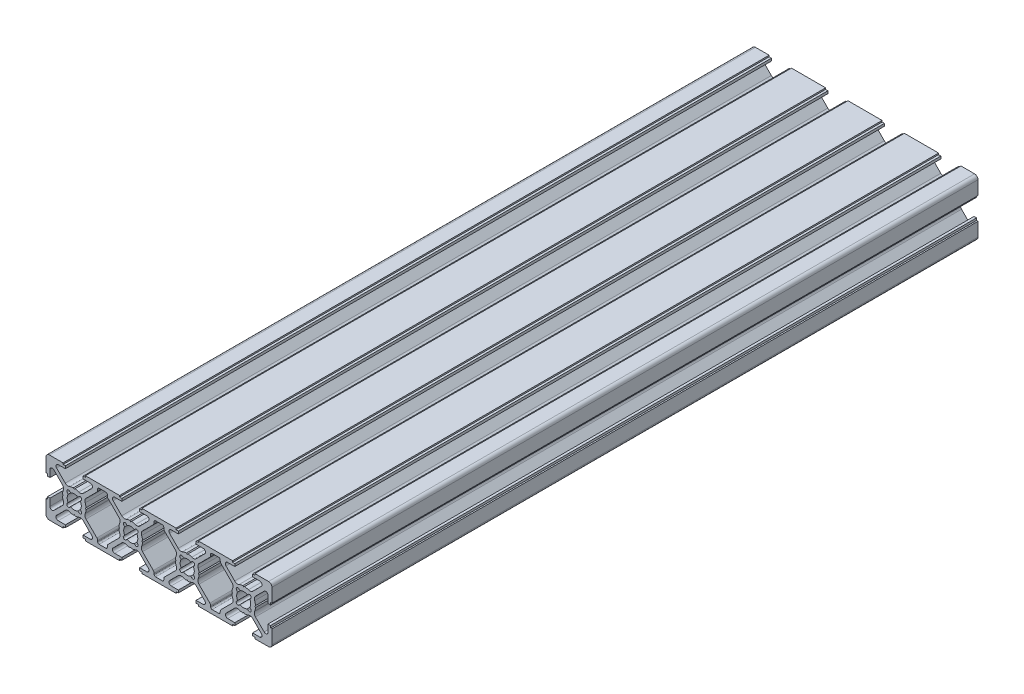
from build123d import *

# Parameters (mm, degrees)
Y_KSEKLIK_EKSTR_ZYON1_DEPTH = 250


with BuildPart() as part:
    # Model → Yükseklik-Ekstrüzyon1 (new body)
    with BuildSketch(Plane.XY):
        with BuildLine():
            Line((-8.800004195, -10.000004195), (-3.950004195, -10.000004195))
            Line((-3.950004195, -10.000004195), (-3.950004195, -9.499995805))
            Line((-3.950004195, -9.499995805), (-3.147504195, -9.499995805))
            Line((-3.147504195, -9.499995805), (-3.147504195, -8.599995805))
            Line((-3.147504195, -8.599995805), (-5.678683852, -8.599995805))
            ThreePointArc((-5.678683852, -8.599995805), (-6.417787478, -8.106142551), (-6.244369277, -7.23431038))
            Line((-6.244369277, -7.23431038), (-3.178748666, -4.168689769))
            ThreePointArc((-3.178748666, -4.168689769), (-2.455097993, -3.783144936), (-1.639430046, -3.866816407))
            ThreePointArc((-1.639430046, -3.866816407), (-0.978142037, -4.084511985), (-0.289977679, -4.189977678))
            Line((-0.289977679, -4.189977678), (0, -3.9))
            Line((0, -3.9), (0.289977678, -4.189977678))
            ThreePointArc((0.289977678, -4.189977678), (0.978142036, -4.084511985), (1.639430046, -3.866816407))
            ThreePointArc((1.639430046, -3.866816407), (2.453899272, -3.782053175), (3.17678595, -4.166734572))
            Line((3.17678595, -4.166734572), (6.244365517, -7.234314139))
            ThreePointArc((6.244365517, -7.234314139), (6.417783718, -8.10614631), (5.678680092, -8.599999564))
            Line((5.678680092, -8.599999564), (3.147500435, -8.599999564))
            Line((3.147500435, -8.599999564), (3.147500435, -9.499999564))
            Line((3.147500435, -9.499999564), (3.950000435, -9.499999564))
            Line((3.950000435, -9.499999564), (3.950000435, -10.000004195))
            Line((3.950000435, -10.000004195), (16.049995805, -10.000004195))
            Line((16.049995805, -10.000004195), (16.049995805, -9.500000435))
            Line((16.049995805, -9.500000435), (16.852495805, -9.500000435))
            Line((16.852495805, -9.500000435), (16.852495805, -8.599995805))
            Line((16.852495805, -8.599995805), (14.321316148, -8.599995805))
            ThreePointArc((14.321316148, -8.599995805), (13.582212522, -8.106142551), (13.755630723, -7.23431038))
            Line((13.755630723, -7.23431038), (16.821251334, -4.168689769))
            ThreePointArc((16.821251334, -4.168689769), (17.544902007, -3.783144936), (18.360569954, -3.866816407))
            ThreePointArc((18.360569954, -3.866816407), (19.021857963, -4.084511985), (19.710022321, -4.189977678))
            Line((19.710022321, -4.189977678), (20, -3.9))
            Line((20, -3.9), (20.289977678, -4.189977678))
            ThreePointArc((20.289977678, -4.189977678), (20.978142036, -4.084511985), (21.639430046, -3.866816407))
            ThreePointArc((21.639430046, -3.866816407), (22.453899272, -3.782053175), (23.17678595, -4.166734572))
            Line((23.17678595, -4.166734572), (26.244365517, -7.234314139))
            ThreePointArc((26.244365517, -7.234314139), (26.417783718, -8.10614631), (25.678680092, -8.599999564))
            Line((25.678680092, -8.599999564), (23.147500435, -8.599999564))
            Line((23.147500435, -8.599999564), (23.147500435, -9.499999564))
            Line((23.147500435, -9.499999564), (23.950000435, -9.499999564))
            Line((23.950000435, -9.499999564), (23.950000435, -10.000004195))
            Line((23.950000435, -10.000004195), (36.049995805, -10.000004195))
            Line((36.049995805, -10.000004195), (36.049995805, -9.500000435))
            Line((36.049995805, -9.500000435), (36.852495805, -9.500000435))
            Line((36.852495805, -9.500000435), (36.852495805, -8.599995805))
            Line((36.852495805, -8.599995805), (34.321316148, -8.599995805))
            ThreePointArc((34.321316148, -8.599995805), (33.582212522, -8.106142551), (33.755630724, -7.23431038))
            Line((33.755630724, -7.23431038), (36.821251334, -4.168689769))
            ThreePointArc((36.821251334, -4.168689769), (37.544902007, -3.783144936), (38.360569954, -3.866816407))
            ThreePointArc((38.360569954, -3.866816407), (39.021857964, -4.084511985), (39.710022322, -4.189977678))
            Line((39.710022322, -4.189977678), (40, -3.9))
            Line((40, -3.9), (40.289977679, -4.189977678))
            ThreePointArc((40.289977679, -4.189977678), (40.978142037, -4.084511985), (41.639430046, -3.866816407))
            ThreePointArc((41.639430046, -3.866816407), (42.453899273, -3.782053175), (43.17678595, -4.166734572))
            Line((43.17678595, -4.166734572), (46.244365517, -7.234314139))
            ThreePointArc((46.244365517, -7.234314139), (46.417783718, -8.10614631), (45.678680092, -8.599999564))
            Line((45.678680092, -8.599999564), (43.147500436, -8.599999564))
            Line((43.147500436, -8.599999564), (43.147500436, -9.499999564))
            Line((43.147500436, -9.499999564), (43.950000436, -9.499999564))
            Line((43.950000436, -9.499999564), (43.950000436, -10.000004195))
            Line((43.950000436, -10.000004195), (56.049995805, -10.000004195))
            Line((56.049995805, -10.000004195), (56.049995805, -9.500000435))
            Line((56.049995805, -9.500000435), (56.852495805, -9.500000435))
            Line((56.852495805, -9.500000435), (56.852495805, -8.599995805))
            Line((56.852495805, -8.599995805), (54.321316148, -8.599995805))
            ThreePointArc((54.321316148, -8.599995805), (53.582212522, -8.106142551), (53.755630723, -7.23431038))
            Line((53.755630723, -7.23431038), (56.821251334, -4.168689769))
            ThreePointArc((56.821251334, -4.168689769), (57.544902007, -3.783144936), (58.360569954, -3.866816407))
            ThreePointArc((58.360569954, -3.866816407), (59.021857963, -4.084511985), (59.710022322, -4.189977678))
            Line((59.710022322, -4.189977678), (60, -3.9))
            Line((60, -3.9), (60.289977678, -4.189977678))
            ThreePointArc((60.289977678, -4.189977678), (60.978142037, -4.084511985), (61.639430046, -3.866816407))
            ThreePointArc((61.639430046, -3.866816407), (62.453899273, -3.782053175), (63.17678595, -4.166734572))
            Line((63.17678595, -4.166734572), (66.244365517, -7.234314139))
            ThreePointArc((66.244365517, -7.234314139), (66.417783718, -8.10614631), (65.678680092, -8.599999564))
            Line((65.678680092, -8.599999564), (63.147500436, -8.599999564))
            Line((63.147500436, -8.599999564), (63.147500436, -9.499999564))
            Line((63.147500436, -9.499999564), (63.950000436, -9.499999564))
            Line((63.950000436, -9.499999564), (63.950000436, -10.000004195))
            Line((63.950000436, -10.000004195), (68.800000436, -10.000004195))
            ThreePointArc((68.800000436, -10.000004195), (69.648528573, -9.648532332), (70.000000435, -8.800004195))
            Line((70.000000435, -8.800004195), (70.000000435, -3.950004195))
            Line((70.000000435, -3.950004195), (69.499995805, -3.950004195))
            Line((69.499995805, -3.950004195), (69.499995805, -3.147739195))
            Line((69.499995805, -3.147739195), (68.599995805, -3.147739195))
            Line((68.599995805, -3.147739195), (68.599995805, -5.678683851))
            ThreePointArc((68.599995805, -5.678683851), (68.106142551, -6.417787477), (67.23431038, -6.244369276))
            Line((67.23431038, -6.244369276), (64.168689769, -3.178748666))
            ThreePointArc((64.168689769, -3.178748666), (63.783144936, -2.455097993), (63.866816407, -1.639430046))
            ThreePointArc((63.866816407, -1.639430046), (64.084511985, -0.978142036), (64.189977678, -0.289977678))
            Line((64.189977678, -0.289977678), (63.9, 0))
            Line((63.9, 0), (64.189977678, 0.289977678))
            ThreePointArc((64.189977678, 0.289977678), (64.084511985, 0.978142037), (63.866816407, 1.639430046))
            ThreePointArc((63.866816407, 1.639430046), (63.782053175, 2.453899272), (64.166734573, 3.17678595))
            Line((64.166734573, 3.17678595), (67.23431414, 6.244365517))
            ThreePointArc((67.23431414, 6.244365517), (68.106146311, 6.417783718), (68.599999565, 5.678680092))
            Line((68.599999565, 5.678680092), (68.599999565, 3.147500436))
            Line((68.599999565, 3.147500436), (69.500000436, 3.147500436))
            Line((69.500000436, 3.147500436), (69.500000436, 3.949999564))
            Line((69.500000436, 3.949999564), (70.000000435, 3.949999564))
            Line((70.000000435, 3.949999564), (70.000000435, 8.799992045))
            ThreePointArc((70.000000435, 8.799992045), (69.648529902, 9.648522613), (68.800000435, 9.999995805))
            Line((68.800000435, 9.999995805), (63.950000435, 9.999995805))
            Line((63.950000435, 9.999995805), (63.950000435, 9.499999564))
            Line((63.950000435, 9.499999564), (63.147500435, 9.499999564))
            Line((63.147500435, 9.499999564), (63.147500435, 8.599999564))
            Line((63.147500435, 8.599999564), (65.678680092, 8.599999564))
            ThreePointArc((65.678680092, 8.599999564), (66.417783718, 8.10614631), (66.244365517, 7.23431414))
            Line((66.244365517, 7.23431414), (63.17678595, 4.166734573))
            ThreePointArc((63.17678595, 4.166734573), (62.453899272, 3.782053175), (61.639430046, 3.866816407))
            ThreePointArc((61.639430046, 3.866816407), (60.978142037, 4.084511985), (60.289977678, 4.189977678))
            Line((60.289977678, 4.189977678), (60, 3.9))
            Line((60, 3.9), (59.710022322, 4.189977679))
            ThreePointArc((59.710022322, 4.189977679), (59.021857964, 4.084511985), (58.360569954, 3.866816407))
            ThreePointArc((58.360569954, 3.866816407), (57.544902007, 3.783144936), (56.821251334, 4.168689769))
            Line((56.821251334, 4.168689769), (53.755630724, 7.23431038))
            ThreePointArc((53.755630724, 7.23431038), (53.582212522, 8.106142551), (54.321316148, 8.599995805))
            Line((54.321316148, 8.599995805), (56.852500435, 8.599995805))
            Line((56.852500435, 8.599995805), (56.852500435, 9.499995805))
            Line((56.852500435, 9.499995805), (56.050000435, 9.499995805))
            Line((56.050000435, 9.499995805), (56.050000435, 9.999995805))
            Line((56.050000435, 9.999995805), (43.950000436, 9.999995805))
            Line((43.950000436, 9.999995805), (43.950000436, 9.499999564))
            Line((43.950000436, 9.499999564), (43.147500436, 9.499999564))
            Line((43.147500436, 9.499999564), (43.147500436, 8.599999564))
            Line((43.147500436, 8.599999564), (45.678680092, 8.599999564))
            ThreePointArc((45.678680092, 8.599999564), (46.417783718, 8.10614631), (46.244365517, 7.234314139))
            Line((46.244365517, 7.234314139), (43.17678595, 4.166734573))
            ThreePointArc((43.17678595, 4.166734573), (42.453899273, 3.782053175), (41.639430046, 3.866816407))
            ThreePointArc((41.639430046, 3.866816407), (40.978142037, 4.084511985), (40.289977679, 4.189977678))
            Line((40.289977679, 4.189977678), (40, 3.9))
            Line((40, 3.9), (39.710022322, 4.189977678))
            ThreePointArc((39.710022322, 4.189977678), (39.021857964, 4.084511985), (38.360569954, 3.866816407))
            ThreePointArc((38.360569954, 3.866816407), (37.544902007, 3.783144936), (36.821251334, 4.168689769))
            Line((36.821251334, 4.168689769), (33.755630724, 7.23431038))
            ThreePointArc((33.755630724, 7.23431038), (33.582212522, 8.106142551), (34.321316149, 8.599995805))
            Line((34.321316149, 8.599995805), (36.852500436, 8.599995805))
            Line((36.852500436, 8.599995805), (36.852500436, 9.499995805))
            Line((36.852500436, 9.499995805), (36.050000436, 9.499995805))
            Line((36.050000436, 9.499995805), (36.050000436, 9.999995805))
            Line((36.050000436, 9.999995805), (23.950000435, 9.999995805))
            Line((23.950000435, 9.999995805), (23.950000435, 9.499999564))
            Line((23.950000435, 9.499999564), (23.147500435, 9.499999564))
            Line((23.147500435, 9.499999564), (23.147500435, 8.599999564))
            Line((23.147500435, 8.599999564), (25.678680092, 8.599999564))
            ThreePointArc((25.678680092, 8.599999564), (26.417783718, 8.10614631), (26.244365517, 7.234314139))
            Line((26.244365517, 7.234314139), (23.17678595, 4.166734573))
            ThreePointArc((23.17678595, 4.166734573), (22.453899272, 3.782053175), (21.639430046, 3.866816407))
            ThreePointArc((21.639430046, 3.866816407), (20.978142036, 4.084511985), (20.289977678, 4.189977678))
            Line((20.289977678, 4.189977678), (20, 3.9))
            Line((20, 3.9), (19.710022321, 4.189977678))
            ThreePointArc((19.710022321, 4.189977678), (19.021857963, 4.084511985), (18.360569954, 3.866816407))
            ThreePointArc((18.360569954, 3.866816407), (17.544902007, 3.783144936), (16.821251334, 4.168689769))
            Line((16.821251334, 4.168689769), (13.755630723, 7.23431038))
            ThreePointArc((13.755630723, 7.23431038), (13.582212522, 8.106142551), (14.321316148, 8.599995805))
            Line((14.321316148, 8.599995805), (16.852500435, 8.599995805))
            Line((16.852500435, 8.599995805), (16.852500435, 9.499995805))
            Line((16.852500435, 9.499995805), (16.050000435, 9.499995805))
            Line((16.050000435, 9.499995805), (16.050000435, 9.999995805))
            Line((16.050000435, 9.999995805), (3.950000435, 9.999995805))
            Line((3.950000435, 9.999995805), (3.950000435, 9.499999565))
            Line((3.950000435, 9.499999565), (3.147500435, 9.499999565))
            Line((3.147500435, 9.499999565), (3.147500435, 8.599999565))
            Line((3.147500435, 8.599999565), (5.678680092, 8.599999565))
            ThreePointArc((5.678680092, 8.599999565), (6.417783718, 8.10614631), (6.244365517, 7.23431414))
            Line((6.244365517, 7.23431414), (3.17678595, 4.166734573))
            ThreePointArc((3.17678595, 4.166734573), (2.453899272, 3.782053175), (1.639430046, 3.866816407))
            ThreePointArc((1.639430046, 3.866816407), (0.978142036, 4.084511985), (0.289977678, 4.189977679))
            Line((0.289977678, 4.189977679), (0, 3.9))
            Line((0, 3.9), (-0.289977679, 4.189977678))
            ThreePointArc((-0.289977679, 4.189977678), (-0.978142037, 4.084511985), (-1.639430046, 3.866816407))
            ThreePointArc((-1.639430046, 3.866816407), (-2.455097993, 3.783144936), (-3.178748666, 4.168689769))
            Line((-3.178748666, 4.168689769), (-6.244369277, 7.23431038))
            ThreePointArc((-6.244369277, 7.23431038), (-6.417787478, 8.106142551), (-5.678683852, 8.599995805))
            Line((-5.678683852, 8.599995805), (-3.147504195, 8.599995805))
            Line((-3.147504195, 8.599995805), (-3.147504195, 9.499995805))
            Line((-3.147504195, 9.499995805), (-3.950004195, 9.499995805))
            Line((-3.950004195, 9.499995805), (-3.950004195, 9.999995805))
            Line((-3.950004195, 9.999995805), (-8.800004195, 9.999995805))
            ThreePointArc((-8.800004195, 9.999995805), (-9.648532333, 9.648523942), (-10.000004195, 8.799995805))
            Line((-10.000004195, 8.799995805), (-10.000004195, 3.949995805))
            Line((-10.000004195, 3.949995805), (-9.500004195, 3.949995805))
            Line((-9.500004195, 3.949995805), (-9.500004195, 3.147495805))
            Line((-9.500004195, 3.147495805), (-8.599999564, 3.147495805))
            Line((-8.599999564, 3.147495805), (-8.599999564, 5.678680092))
            ThreePointArc((-8.599999564, 5.678680092), (-8.10614631, 6.417783718), (-7.234314139, 6.244365517))
            Line((-7.234314139, 6.244365517), (-4.166734573, 3.17678595))
            ThreePointArc((-4.166734573, 3.17678595), (-3.782053175, 2.453899272), (-3.866816407, 1.639430046))
            ThreePointArc((-3.866816407, 1.639430046), (-4.084511985, 0.978142037), (-4.189977678, 0.289977678))
            Line((-4.189977678, 0.289977678), (-3.9, 0))
            Line((-3.9, 0), (-4.189977678, -0.289977678))
            ThreePointArc((-4.189977678, -0.289977678), (-4.084511985, -0.978142036), (-3.866816407, -1.639430046))
            ThreePointArc((-3.866816407, -1.639430046), (-3.783144936, -2.455097993), (-4.168689769, -3.178748666))
            Line((-4.168689769, -3.178748666), (-7.23431038, -6.244369276))
            ThreePointArc((-7.23431038, -6.244369276), (-8.106142551, -6.417787477), (-8.599995805, -5.678683851))
            Line((-8.599995805, -5.678683851), (-8.599995805, -3.147504195))
            Line((-8.599995805, -3.147504195), (-9.499995805, -3.147504195))
            Line((-9.499995805, -3.147504195), (-9.499995805, -3.950004195))
            Line((-9.499995805, -3.950004195), (-10.000004195, -3.950004195))
            Line((-10.000004195, -3.950004195), (-10.000004195, -8.800004195))
            ThreePointArc((-10.000004195, -8.800004195), (-9.648532333, -9.648532332), (-8.800004195, -10.000004195))
        make_face()
        with BuildLine():
            Line((62.140364299, 1.291836162), (62.474873734, 1.626345597))
            ThreePointArc((62.474873734, 1.626345597), (62.474873734, 2.474873734), (61.626345597, 2.474873734))
            Line((61.626345597, 2.474873734), (61.291836161, 2.140364299))
            ThreePointArc((61.291836161, 2.140364299), (60, 2.5), (58.708163839, 2.140364299))
            Line((58.708163839, 2.140364299), (58.373654403, 2.474873734))
            ThreePointArc((58.373654403, 2.474873734), (57.525126266, 2.474873734), (57.525126266, 1.626345597))
            Line((57.525126266, 1.626345597), (57.859635701, 1.291836162))
            ThreePointArc((57.859635701, 1.291836162), (57.5, 0), (57.859635701, -1.291836161))
            Line((57.859635701, -1.291836161), (57.525126266, -1.626345597))
            ThreePointArc((57.525126266, -1.626345597), (57.525126266, -2.474873734), (58.373654403, -2.474873734))
            Line((58.373654403, -2.474873734), (58.708163839, -2.140364299))
            ThreePointArc((58.708163839, -2.140364299), (60, -2.5), (61.291836162, -2.140364299))
            Line((61.291836162, -2.140364299), (61.626345597, -2.474873734))
            ThreePointArc((61.626345597, -2.474873734), (62.474873734, -2.474873734), (62.474873734, -1.626345597))
            Line((62.474873734, -1.626345597), (62.140364299, -1.291836161))
            ThreePointArc((62.140364299, -1.291836161), (62.5, 0), (62.140364299, 1.291836162))
        make_face(mode=Mode.SUBTRACT)
        with BuildLine():
            Line((55.834194285, -3.175856222), (51.989949494, -7.020101012))
            ThreePointArc((51.989949494, -7.020101012), (51.773176743, -7.344524361), (51.697056275, -7.727207794))
            Line((51.697056275, -7.727207794), (51.697056275, -8.1))
            ThreePointArc((51.697056275, -8.1), (51.550609666, -8.453553391), (51.197056275, -8.6))
            Line((51.197056275, -8.6), (48.802943725, -8.6))
            ThreePointArc((48.802943725, -8.6), (48.449390335, -8.453553391), (48.302943725, -8.1))
            Line((48.302943725, -8.1), (48.302943725, -7.727207794))
            ThreePointArc((48.302943725, -7.727207794), (48.226823258, -7.344524362), (48.010050506, -7.020101013))
            Line((48.010050506, -7.020101013), (44.165805715, -3.175856222))
            ThreePointArc((44.165805715, -3.175856222), (43.781533861, -2.453330896), (43.866816407, -1.639430046))
            ThreePointArc((43.866816407, -1.639430046), (44.084511985, -0.978142037), (44.189977678, -0.289977678))
            Line((44.189977678, -0.289977678), (43.9, 0))
            Line((43.9, 0), (44.189977678, 0.289977678))
            ThreePointArc((44.189977678, 0.289977678), (44.084511985, 0.978142037), (43.866816407, 1.639430046))
            ThreePointArc((43.866816407, 1.639430046), (43.781533861, 2.453330896), (44.165805715, 3.175856222))
            Line((44.165805715, 3.175856222), (48.010050506, 7.020101013))
            ThreePointArc((48.010050506, 7.020101013), (48.226823258, 7.344524362), (48.302943725, 7.727207794))
            Line((48.302943725, 7.727207794), (48.302943725, 8.1))
            ThreePointArc((48.302943725, 8.1), (48.449390335, 8.453553391), (48.802943725, 8.6))
            Line((48.802943725, 8.6), (51.197056275, 8.6))
            ThreePointArc((51.197056275, 8.6), (51.550609665, 8.453553391), (51.697056275, 8.1))
            Line((51.697056275, 8.1), (51.697056275, 7.727207794))
            ThreePointArc((51.697056275, 7.727207794), (51.773176742, 7.344524361), (51.989949494, 7.020101013))
            Line((51.989949494, 7.020101013), (55.834194285, 3.175856222))
            ThreePointArc((55.834194285, 3.175856222), (56.218466139, 2.453330896), (56.133183593, 1.639430046))
            ThreePointArc((56.133183593, 1.639430046), (55.915488015, 0.978142037), (55.810022322, 0.289977678))
            Line((55.810022322, 0.289977678), (56.1, 0))
            Line((56.1, 0), (55.810022322, -0.289977678))
            ThreePointArc((55.810022322, -0.289977678), (55.915488015, -0.978142037), (56.133183593, -1.639430046))
            ThreePointArc((56.133183593, -1.639430046), (56.218466139, -2.453330896), (55.834194285, -3.175856222))
        make_face(mode=Mode.SUBTRACT)
        with BuildLine():
            Line((-2.140364299, 1.291836161), (-2.474873734, 1.626345597))
            ThreePointArc((-2.474873734, 1.626345597), (-2.474873734, 2.474873734), (-1.626345597, 2.474873734))
            Line((-1.626345597, 2.474873734), (-1.291836161, 2.140364299))
            ThreePointArc((-1.291836161, 2.140364299), (0, 2.5), (1.291836161, 2.140364299))
            Line((1.291836161, 2.140364299), (1.626345596, 2.474873734))
            ThreePointArc((1.626345596, 2.474873734), (2.474873734, 2.474873734), (2.474873734, 1.626345597))
            Line((2.474873734, 1.626345597), (2.140364299, 1.291836162))
            ThreePointArc((2.140364299, 1.291836162), (2.5, 0), (2.140364299, -1.291836161))
            Line((2.140364299, -1.291836161), (2.474873734, -1.626345597))
            ThreePointArc((2.474873734, -1.626345597), (2.474873734, -2.474873734), (1.626345597, -2.474873734))
            Line((1.626345597, -2.474873734), (1.291836161, -2.140364299))
            ThreePointArc((1.291836161, -2.140364299), (0, -2.5), (-1.291836162, -2.140364299))
            Line((-1.291836162, -2.140364299), (-1.626345597, -2.474873734))
            ThreePointArc((-1.626345597, -2.474873734), (-2.474873734, -2.474873734), (-2.474873734, -1.626345597))
            Line((-2.474873734, -1.626345597), (-2.140364299, -1.291836161))
            ThreePointArc((-2.140364299, -1.291836161), (-2.5, 0), (-2.140364299, 1.291836161))
        make_face(mode=Mode.SUBTRACT)
        with BuildLine():
            Line((4.165805715, -3.175856222), (8.010050506, -7.020101012))
            ThreePointArc((8.010050506, -7.020101012), (8.226823257, -7.344524361), (8.302943725, -7.727207794))
            Line((8.302943725, -7.727207794), (8.302943725, -8.1))
            ThreePointArc((8.302943725, -8.1), (8.449390334, -8.45355339), (8.802943725, -8.6))
            Line((8.802943725, -8.6), (11.197056275, -8.6))
            ThreePointArc((11.197056275, -8.6), (11.550609665, -8.453553391), (11.697056275, -8.1))
            Line((11.697056275, -8.1), (11.697056275, -7.727207794))
            ThreePointArc((11.697056275, -7.727207794), (11.773176742, -7.344524362), (11.989949494, -7.020101013))
            Line((11.989949494, -7.020101013), (15.834194285, -3.175856222))
            ThreePointArc((15.834194285, -3.175856222), (16.218466139, -2.453330896), (16.133183593, -1.639430046))
            ThreePointArc((16.133183593, -1.639430046), (15.915488015, -0.978142037), (15.810022322, -0.289977678))
            Line((15.810022322, -0.289977678), (16.1, 0))
            Line((16.1, 0), (15.810022321, 0.289977678))
            ThreePointArc((15.810022321, 0.289977678), (15.915488015, 0.978142037), (16.133183593, 1.639430046))
            ThreePointArc((16.133183593, 1.639430046), (16.218466139, 2.453330896), (15.834194284, 3.175856222))
            Line((15.834194284, 3.175856222), (11.989949494, 7.020101013))
            ThreePointArc((11.989949494, 7.020101013), (11.773176742, 7.344524362), (11.697056275, 7.727207794))
            Line((11.697056275, 7.727207794), (11.697056275, 8.1))
            ThreePointArc((11.697056275, 8.1), (11.550609665, 8.453553391), (11.197056275, 8.6))
            Line((11.197056275, 8.6), (8.802943725, 8.6))
            ThreePointArc((8.802943725, 8.6), (8.449390334, 8.453553391), (8.302943725, 8.1))
            Line((8.302943725, 8.1), (8.302943725, 7.727207794))
            ThreePointArc((8.302943725, 7.727207794), (8.226823258, 7.344524362), (8.010050506, 7.020101013))
            Line((8.010050506, 7.020101013), (4.165805715, 3.175856222))
            ThreePointArc((4.165805715, 3.175856222), (3.78153386, 2.453330896), (3.866816407, 1.639430046))
            ThreePointArc((3.866816407, 1.639430046), (4.084511985, 0.978142037), (4.189977678, 0.289977678))
            Line((4.189977678, 0.289977678), (3.9, 0))
            Line((3.9, 0), (4.189977678, -0.289977678))
            ThreePointArc((4.189977678, -0.289977678), (4.084511985, -0.978142037), (3.866816407, -1.639430046))
            ThreePointArc((3.866816407, -1.639430046), (3.781533861, -2.453330896), (4.165805715, -3.175856222))
        make_face(mode=Mode.SUBTRACT)
        with BuildLine():
            Line((17.859635701, 1.291836161), (17.525126266, 1.626345597))
            ThreePointArc((17.525126266, 1.626345597), (17.525126266, 2.474873734), (18.373654403, 2.474873734))
            Line((18.373654403, 2.474873734), (18.708163838, 2.140364299))
            ThreePointArc((18.708163838, 2.140364299), (20, 2.5), (21.291836161, 2.140364299))
            Line((21.291836161, 2.140364299), (21.626345597, 2.474873734))
            ThreePointArc((21.626345597, 2.474873734), (22.474873734, 2.474873734), (22.474873734, 1.626345597))
            Line((22.474873734, 1.626345597), (22.140364299, 1.291836161))
            ThreePointArc((22.140364299, 1.291836161), (22.5, 0), (22.140364299, -1.291836161))
            Line((22.140364299, -1.291836161), (22.474873734, -1.626345597))
            ThreePointArc((22.474873734, -1.626345597), (22.474873734, -2.474873734), (21.626345597, -2.474873734))
            Line((21.626345597, -2.474873734), (21.291836161, -2.140364299))
            ThreePointArc((21.291836161, -2.140364299), (20, -2.5), (18.708163838, -2.140364299))
            Line((18.708163838, -2.140364299), (18.373654403, -2.474873734))
            ThreePointArc((18.373654403, -2.474873734), (17.525126266, -2.474873734), (17.525126266, -1.626345597))
            Line((17.525126266, -1.626345597), (17.859635701, -1.291836161))
            ThreePointArc((17.859635701, -1.291836161), (17.5, 0), (17.859635701, 1.291836161))
        make_face(mode=Mode.SUBTRACT)
        with BuildLine():
            Line((37.859635701, 1.291836161), (37.525126266, 1.626345597))
            ThreePointArc((37.525126266, 1.626345597), (37.525126266, 2.474873734), (38.373654403, 2.474873734))
            Line((38.373654403, 2.474873734), (38.708163839, 2.140364299))
            ThreePointArc((38.708163839, 2.140364299), (40, 2.5), (41.291836162, 2.140364299))
            Line((41.291836162, 2.140364299), (41.626345597, 2.474873734))
            ThreePointArc((41.626345597, 2.474873734), (42.474873734, 2.474873734), (42.474873734, 1.626345597))
            Line((42.474873734, 1.626345597), (42.140364299, 1.291836161))
            ThreePointArc((42.140364299, 1.291836161), (42.5, 0), (42.140364299, -1.291836161))
            Line((42.140364299, -1.291836161), (42.474873734, -1.626345597))
            ThreePointArc((42.474873734, -1.626345597), (42.474873734, -2.474873734), (41.626345597, -2.474873734))
            Line((41.626345597, -2.474873734), (41.291836162, -2.140364299))
            ThreePointArc((41.291836162, -2.140364299), (40, -2.5), (38.708163839, -2.140364299))
            Line((38.708163839, -2.140364299), (38.373654403, -2.474873734))
            ThreePointArc((38.373654403, -2.474873734), (37.525126266, -2.474873734), (37.525126266, -1.626345597))
            Line((37.525126266, -1.626345597), (37.859635701, -1.291836161))
            ThreePointArc((37.859635701, -1.291836161), (37.5, 0), (37.859635701, 1.291836161))
        make_face(mode=Mode.SUBTRACT)
        with BuildLine():
            Line((24.165805716, -3.175856222), (28.010050507, -7.020101013))
            ThreePointArc((28.010050507, -7.020101013), (28.226823258, -7.344524362), (28.302943726, -7.727207794))
            Line((28.302943726, -7.727207794), (28.302943726, -8.1))
            ThreePointArc((28.302943726, -8.1), (28.449390335, -8.453553391), (28.802943726, -8.6))
            Line((28.802943726, -8.6), (31.197056275, -8.6))
            ThreePointArc((31.197056275, -8.6), (31.550609666, -8.453553391), (31.697056275, -8.1))
            Line((31.697056275, -8.1), (31.697056275, -7.727207794))
            ThreePointArc((31.697056275, -7.727207794), (31.773176743, -7.344524362), (31.989949494, -7.020101013))
            Line((31.989949494, -7.020101013), (35.834194285, -3.175856222))
            ThreePointArc((35.834194285, -3.175856222), (36.21846614, -2.453330896), (36.133183594, -1.639430046))
            ThreePointArc((36.133183594, -1.639430046), (35.915488015, -0.978142037), (35.810022322, -0.289977678))
            Line((35.810022322, -0.289977678), (36.1, 0))
            Line((36.1, 0), (35.810022322, 0.289977678))
            ThreePointArc((35.810022322, 0.289977678), (35.915488015, 0.978142037), (36.133183594, 1.639430046))
            ThreePointArc((36.133183594, 1.639430046), (36.21846614, 2.453330896), (35.834194285, 3.175856222))
            Line((35.834194285, 3.175856222), (31.989949494, 7.020101013))
            ThreePointArc((31.989949494, 7.020101013), (31.773176743, 7.344524362), (31.697056275, 7.727207794))
            Line((31.697056275, 7.727207794), (31.697056275, 8.1))
            ThreePointArc((31.697056275, 8.1), (31.550609666, 8.453553391), (31.197056275, 8.6))
            Line((31.197056275, 8.6), (28.802943725, 8.6))
            ThreePointArc((28.802943725, 8.6), (28.449390335, 8.453553391), (28.302943725, 8.1))
            Line((28.302943725, 8.1), (28.302943725, 7.727207794))
            ThreePointArc((28.302943725, 7.727207794), (28.226823258, 7.344524361), (28.010050507, 7.020101013))
            Line((28.010050507, 7.020101013), (24.165805716, 3.175856222))
            ThreePointArc((24.165805716, 3.175856222), (23.781533861, 2.453330896), (23.866816407, 1.639430046))
            ThreePointArc((23.866816407, 1.639430046), (24.084511985, 0.978142037), (24.189977679, 0.289977678))
            Line((24.189977679, 0.289977678), (23.9, 0))
            Line((23.9, 0), (24.189977679, -0.289977678))
            ThreePointArc((24.189977679, -0.289977678), (24.084511985, -0.978142037), (23.866816407, -1.639430046))
            ThreePointArc((23.866816407, -1.639430046), (23.781533861, -2.453330896), (24.165805716, -3.175856222))
        make_face(mode=Mode.SUBTRACT)
    extrude(amount=-Y_KSEKLIK_EKSTR_ZYON1_DEPTH)


solid = part.part
